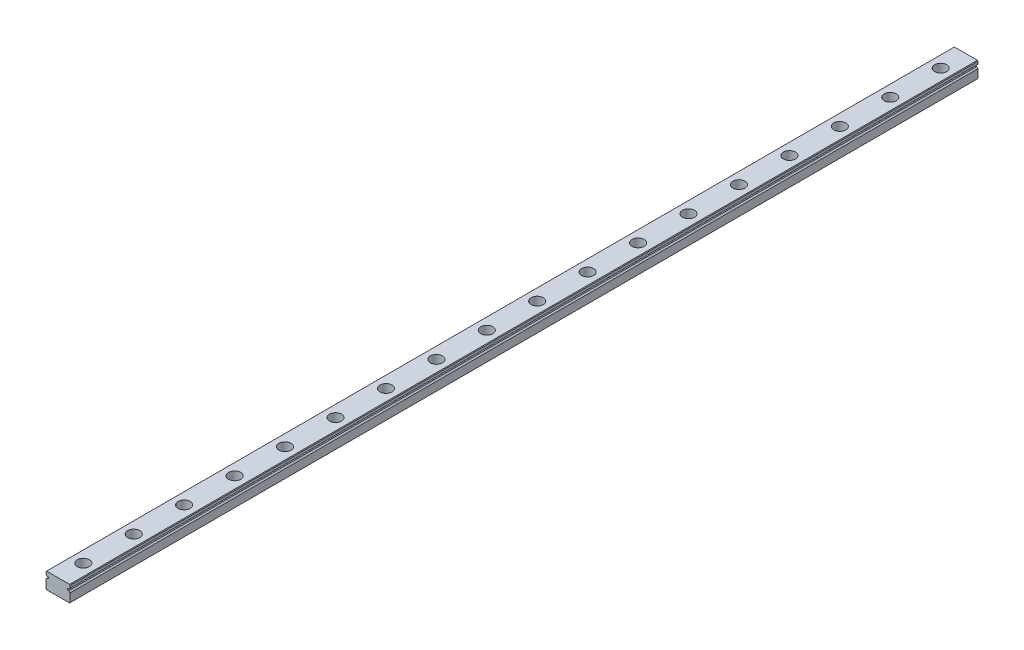
from build123d import *

# Parameters (mm, degrees)
EXTRUDE_1_DEPTH        = 450
SKETCH_2_R             = 3
SKETCH_2_R_2           = 1.75
CUT_EXTRUDE_1_DEPTH    = 4.5
SKETCH_2_2_R           = 1.75
CUT_EXTRUDE_2_DEPTH    = 9
PATTERN_LINEAR_1_COUNT = 18
PATTERN_LINEAR_1_PITCH = 25


with BuildPart() as part:
    # Эскиз1 → Бобышка-Вытянуть1 (new body)
    with BuildSketch(Plane.XY):
        with BuildLine():
            Line((-6, 3.7), (-5.7, 4))
            Line((-5.7, 4), (5.7, 4))
            Line((5.7, 4), (6, 3.7))
            Line((6, 3.7), (6, 2.451013544))
            ThreePointArc((6, 2.451013544), (5.597935912, 2.202976267), (5.354599002, 1.798050138))
            Line((5.354599002, 1.798050138), (4.643514056, 1.798050138))
            Line((4.643514056, 1.798050138), (4.643514056, 1.201949862))
            Line((4.643514056, 1.201949862), (5.354599002, 1.201949862))
            ThreePointArc((5.354599002, 1.201949862), (5.597935912, 0.797023733), (6, 0.548986456))
            Line((6, 0.548986456), (6, -3.7))
            Line((6, -3.7), (5.7, -4))
            Line((5.7, -4), (-5.7, -4))
            Line((-5.7, -4), (-6, -3.7))
            Line((-6, -3.7), (-6, 0.548986456))
            ThreePointArc((-6, 0.548986456), (-5.597935912, 0.797023733), (-5.354599002, 1.201949862))
            Line((-5.354599002, 1.201949862), (-4.643514056, 1.201949862))
            Line((-4.643514056, 1.201949862), (-4.643514056, 1.798050138))
            Line((-4.643514056, 1.798050138), (-5.354599002, 1.798050138))
            ThreePointArc((-5.354599002, 1.798050138), (-5.597935912, 2.202976267), (-6, 2.451013544))
            Line((-6, 2.451013544), (-6, 3.7))
        make_face()
    extrude(amount=EXTRUDE_1_DEPTH)

    # Эскиз2 → Вырез-Вытянуть1 (cut)
    with BuildSketch(Plane(origin=(0, 4, 0), x_dir=(1, 0, 0), z_dir=(0, 1, 0))):
        with Locations((0, -12.5)):
            Circle(SKETCH_2_R)
        with Locations((0, -12.5)):
            Circle(SKETCH_2_R_2, mode=Mode.SUBTRACT)
    cut_extrude_1 = extrude(amount=-CUT_EXTRUDE_1_DEPTH, mode=Mode.SUBTRACT)

    # Эскиз2<2> → Вырез-Вытянуть2 (cut, through all)
    with BuildSketch(Plane(origin=(0, 4, 0), x_dir=(1, 0, 0), z_dir=(0, 1, 0))):
        with Locations((0, -12.5)):
            Circle(SKETCH_2_2_R)
    cut_extrude_2 = extrude(amount=-CUT_EXTRUDE_2_DEPTH, mode=Mode.SUBTRACT)

    # Линейный массив1: Вырез-Вытянуть1, Вырез-Вытянуть2 ×18
    with Locations(*[(0, 0, i * PATTERN_LINEAR_1_PITCH) for i in range(1, PATTERN_LINEAR_1_COUNT)]):
        add(cut_extrude_1, mode=Mode.SUBTRACT)
        add(cut_extrude_2, mode=Mode.SUBTRACT)


solid = part.part
